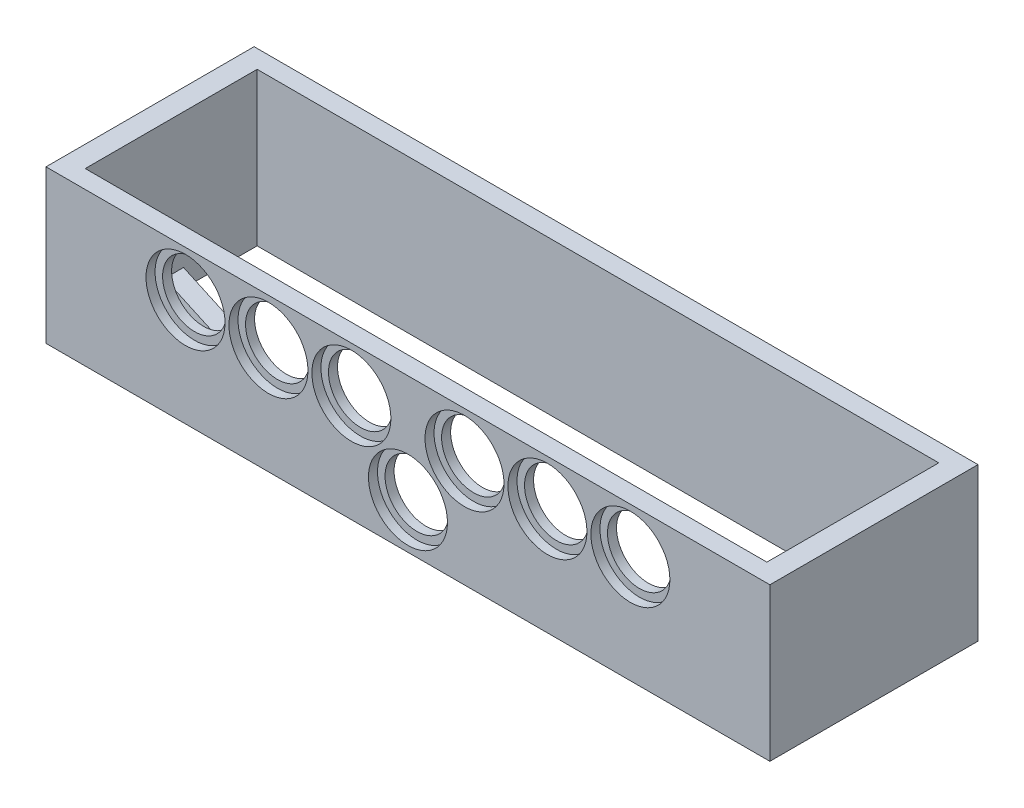
from build123d import *

# Parameters (mm, degrees)
SKICA1_W                 = 240
SKICA1_H                 = 69
SKICA1_W_2               = 226
SKICA1_H_2               = 57
P_IDAT_VYSUNUT_M1_DEPTH  = 50.7
SKICA2_R                 = 13.1
ODEBRAT_VYSUNUT_M1_DEPTH = 3
SKICA4_R                 = 10.6
ODEBRAT_VYSUNUT_M2_DEPTH = 6
P_IDAT_VYSUNUT_M2_DEPTH  = 6


with BuildPart() as part:
    # Skica1 → Přidat vysunutím1 (new body)
    with BuildSketch(Plane(origin=(0, 0, 0), x_dir=(1, 0, 0), z_dir=(0, 1, 0))):
        with Locations((120, 34.5)):
            Rectangle(SKICA1_W, SKICA1_H)
        with Locations((120, 34.5)):
            Rectangle(SKICA1_W_2, SKICA1_H_2, mode=Mode.SUBTRACT)
    extrude(amount=P_IDAT_VYSUNUT_M1_DEPTH)

    # Skica2 → Odebrat vysunutím1 (cut)
    with BuildSketch(Plane.XY):
        with Locations((46.25, 35.6)):
            Circle(SKICA2_R)
        with Locations((73.75, 35.6)):
            Circle(SKICA2_R)
        with Locations((101.25, 35.6)):
            Circle(SKICA2_R)
        with Locations((138.75, 35.6)):
            Circle(SKICA2_R)
        with Locations((166.25, 35.6)):
            Circle(SKICA2_R)
        with Locations((193.75, 35.6)):
            Circle(SKICA2_R)
        with Locations((120, 15.1)):
            Circle(SKICA2_R)
    extrude(amount=-ODEBRAT_VYSUNUT_M1_DEPTH, mode=Mode.SUBTRACT)

    # Skica4 → Odebrat vysunutím2 (cut)
    with BuildSketch(Plane.XY):
        with Locations((46.25, 35.6)):
            Circle(SKICA4_R)
        with Locations((73.75, 35.6)):
            Circle(SKICA4_R)
        with Locations((138.75, 35.6)):
            Circle(SKICA4_R)
        with Locations((101.25, 35.6)):
            Circle(SKICA4_R)
        with Locations((120, 15.1)):
            Circle(SKICA4_R)
        with Locations((166.25, 35.6)):
            Circle(SKICA4_R)
        with Locations((193.75, 35.6)):
            Circle(SKICA4_R)
    extrude(amount=-ODEBRAT_VYSUNUT_M2_DEPTH, mode=Mode.SUBTRACT)

    # Skica5 → Přidat vysunutím2 (add)
    with BuildSketch(Plane.XZ):
        Polygon((149.130434783, -6), (129.075362319, -6), (233, -38.594545455), (233, -32.304545455), align=None)
        Polygon((90.869565217, -6), (7, -32.304545455), (7, -38.594545455), (110.924637681, -6), align=None)
    extrude(amount=-P_IDAT_VYSUNUT_M2_DEPTH)


solid = part.part
